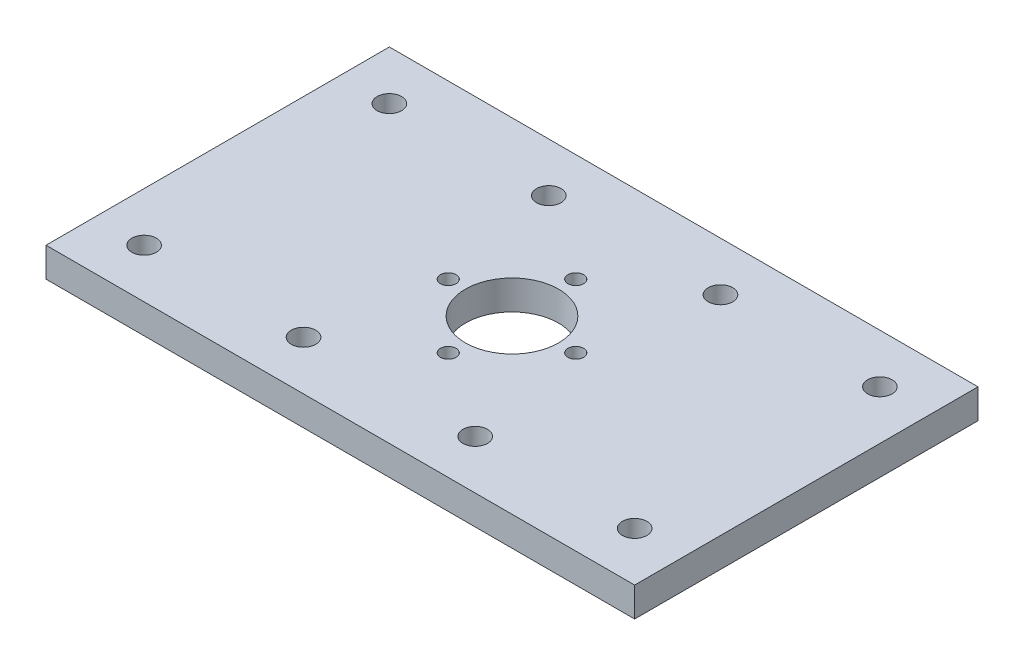
from build123d import *

# Parameters (mm, degrees)
SKETCH1_W                                       = 120
SKETCH1_H                                       = 70
SKETCH1_R                                       = 9.5
SKETCH1_R_2                                     = 2.5
BOSS_EXTRUDE1_DEPTH                             = 6
CSK_FOR_M3_FLAT_HEAD_MACHINE_SCREW1_D           = 3.2
CSK_FOR_M3_FLAT_HEAD_MACHINE_SCREW1_CSINK_D     = 6.3
CSK_FOR_M3_FLAT_HEAD_MACHINE_SCREW1_CSINK_ANGLE = 90


with BuildPart() as part:
    # Sketch1 → Boss-Extrude1 (new body)
    with BuildSketch(Plane(origin=(0, 0, 0), x_dir=(1, 0, 0), z_dir=(0, 1, 0))):
        Rectangle(SKETCH1_W, SKETCH1_H)
        Circle(SKETCH1_R, mode=Mode.SUBTRACT)
        with Locations((-17.5, 25)):
            Circle(SKETCH1_R_2, mode=Mode.SUBTRACT)
        with Locations((17.5, 25)):
            Circle(SKETCH1_R_2, mode=Mode.SUBTRACT)
        with Locations((17.5, -25)):
            Circle(SKETCH1_R_2, mode=Mode.SUBTRACT)
        with Locations((-17.5, -25)):
            Circle(SKETCH1_R_2, mode=Mode.SUBTRACT)
        with Locations((-50, 25)):
            Circle(SKETCH1_R_2, mode=Mode.SUBTRACT)
        with Locations((-50, -25)):
            Circle(SKETCH1_R_2, mode=Mode.SUBTRACT)
        with Locations((50, -25)):
            Circle(SKETCH1_R_2, mode=Mode.SUBTRACT)
        with Locations((50, 25)):
            Circle(SKETCH1_R_2, mode=Mode.SUBTRACT)
    extrude(amount=BOSS_EXTRUDE1_DEPTH)

    # CSK for M3 Flat Head Machine Screw1 (through all)
    with Locations(Plane(origin=(0, 0, 0), x_dir=(-1, 0, 0), z_dir=(0, -1, 0))):
        with Locations((-13, 0), (0, -13), (13, 0), (0, 13)):
            CounterSinkHole(CSK_FOR_M3_FLAT_HEAD_MACHINE_SCREW1_D / 2, CSK_FOR_M3_FLAT_HEAD_MACHINE_SCREW1_CSINK_D / 2, counter_sink_angle=CSK_FOR_M3_FLAT_HEAD_MACHINE_SCREW1_CSINK_ANGLE)


solid = part.part
